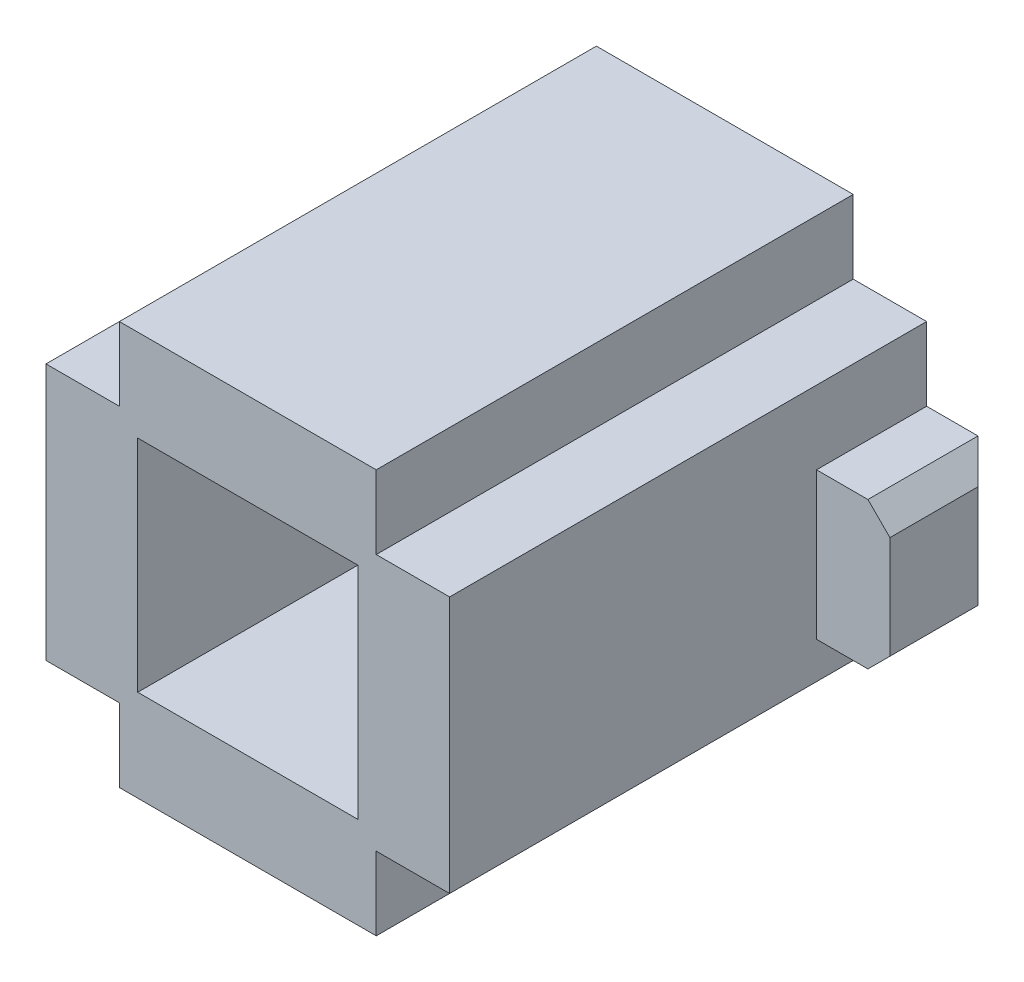
from build123d import *

# Parameters (mm, degrees)
SKETCH1_W           = 30
SKETCH1_H           = 30
BOSS_EXTRUDE1_DEPTH = 32.5
SKETCH2_W           = 15
SKETCH2_H           = 20
BOSS_EXTRUDE2_DEPTH = 10
CHAMFER1_SIZE       = 3


with BuildPart() as part:
    # Sketch1 → Boss-Extrude1 (new body, symmetric)
    with BuildSketch(Plane.XY):
        Polygon((-17.5, 27.5), (17.5, 27.5), (17.5, 17.5), (27.5, 17.5), (27.5, -17.5), (17.5, -17.5), (17.5, -27.5), (-17.5, -27.5), (-17.5, -17.5), (-27.5, -17.5), (-27.5, 17.5), (-17.5, 17.5), align=None)
        Rectangle(SKETCH1_W, SKETCH1_H, mode=Mode.SUBTRACT)
    extrude(amount=BOSS_EXTRUDE1_DEPTH, both=True)

    # Sketch2 → Boss-Extrude2 (add)
    with BuildSketch(Plane(origin=(27.5, 0, 0), x_dir=(0, 0, -1), z_dir=(1, 0, 0))):
        with Locations((25, -2.5)):
            Rectangle(SKETCH2_W, SKETCH2_H)
    extrude(amount=BOSS_EXTRUDE2_DEPTH)

    # Chamfer1
    chamfer1_edges = [part.edges().sort_by_distance(p)[0] for p in [
        (37.5, -2.5, -32.5),
        (37.5, 7.5, -25),
        (37.5, -12.5, -25),
    ]]
    chamfer(chamfer1_edges, length=CHAMFER1_SIZE)


solid = part.part
